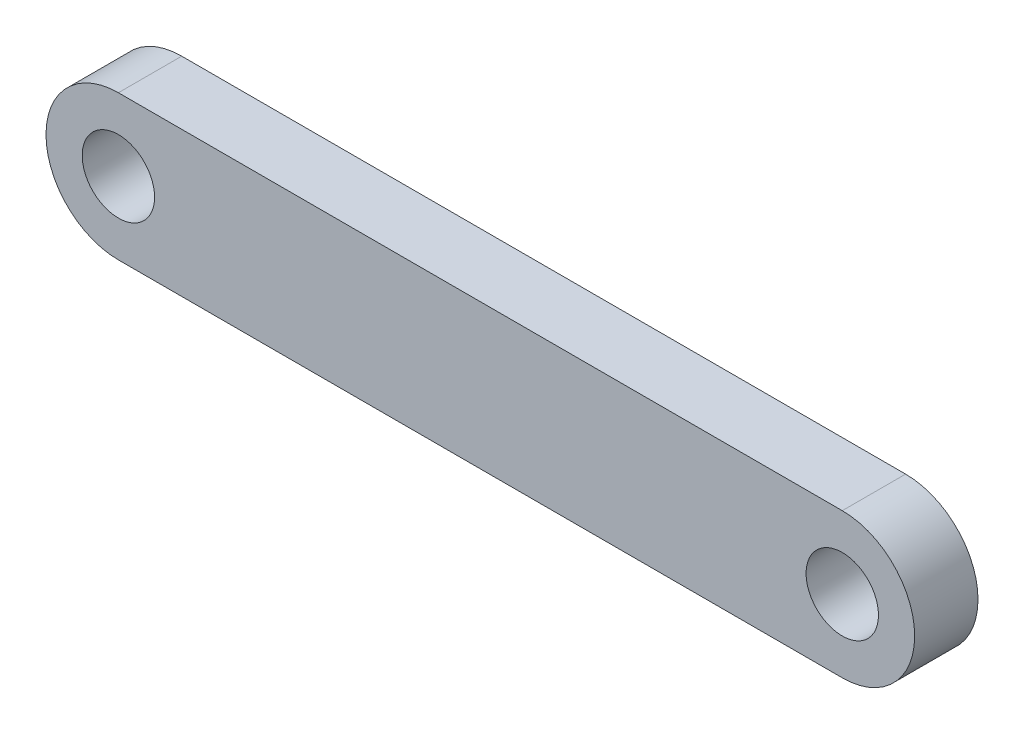
from build123d import *

# Parameters (mm, degrees)
SCHIZZO1_R                   = 5
ESTRUSIONE_ESTRUSIONE1_DEPTH = 8.75


with BuildPart() as part:
    # Schizzo1 → Estrusione-Estrusione1 (new body)
    with BuildSketch(Plane.XY):
        with BuildLine():
            Line((0, 10), (100, 10))
            ThreePointArc((100, 10), (110, 0), (100, -10))
            Line((100, -10), (0, -10))
            ThreePointArc((0, -10), (-10, 0), (0, 10))
        make_face()
        Circle(SCHIZZO1_R, mode=Mode.SUBTRACT)
        with Locations((100, 0)):
            Circle(SCHIZZO1_R, mode=Mode.SUBTRACT)
    extrude(amount=ESTRUSIONE_ESTRUSIONE1_DEPTH)


solid = part.part
